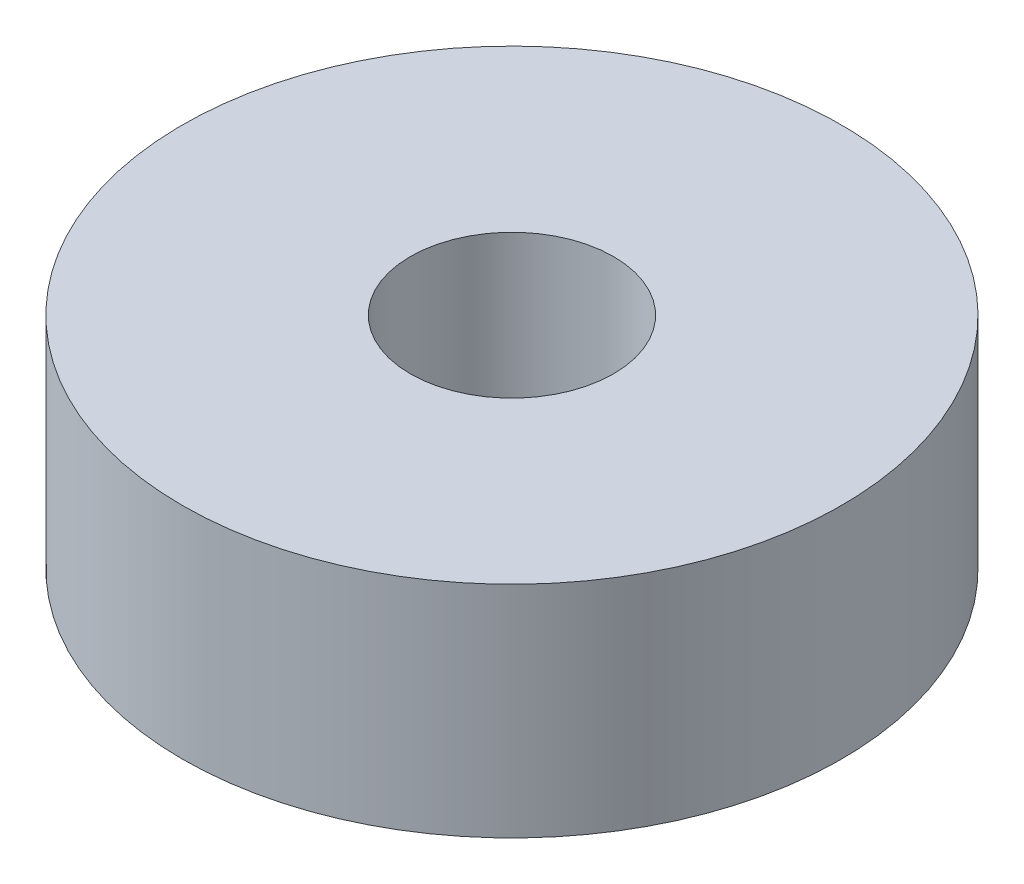
from build123d import *

# Parameters (mm, degrees)
SKETCH1_R           = 6
SKETCH1_R_2         = 1.85
BOSS_EXTRUDE1_DEPTH = 2


with BuildPart() as part:
    # Sketch1 → Boss-Extrude1 (new body, symmetric)
    with BuildSketch(Plane(origin=(0, 0, 0), x_dir=(1, 0, 0), z_dir=(0, 1, 0))):
        Circle(SKETCH1_R)
        Circle(SKETCH1_R_2, mode=Mode.SUBTRACT)
    extrude(amount=BOSS_EXTRUDE1_DEPTH, both=True)


solid = part.part
